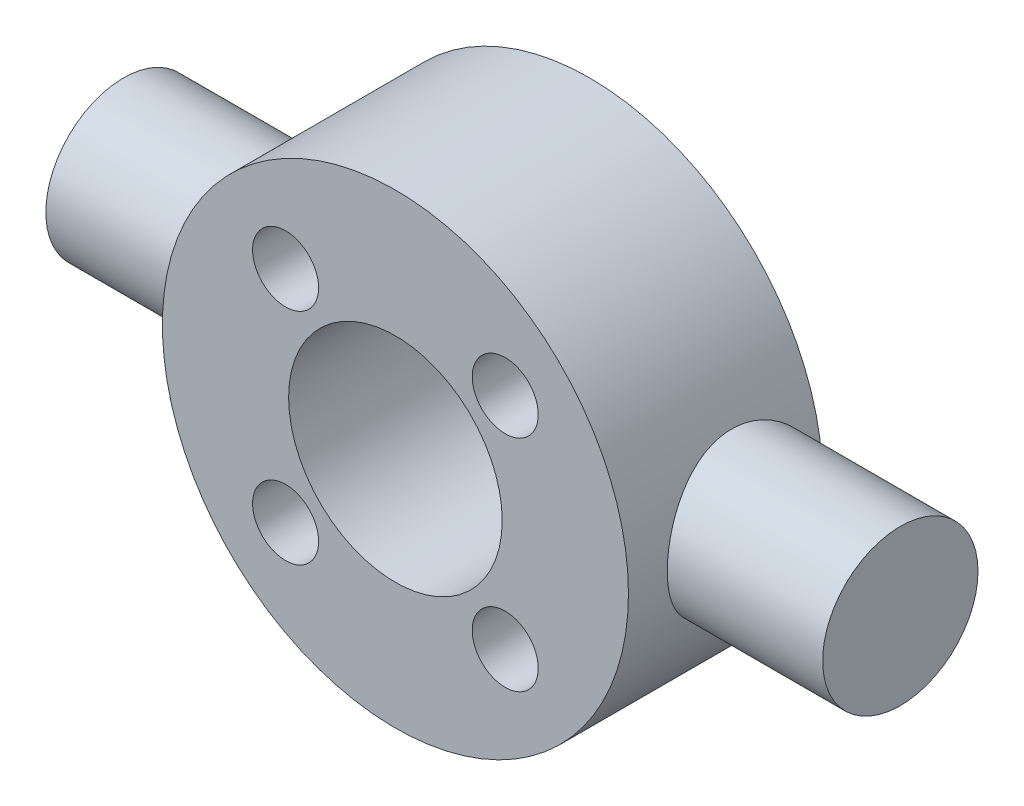
from build123d import *

# Parameters (mm, degrees)
CROQUIS1_R              = 12
CROQUIS1_R_2            = 1.7
SALIENTE_EXTRUIR1_DEPTH = 10
CROQUIS2_R              = 4
SALIENTE_EXTRUIR2_DEPTH = 20
CORTAR_EXTRUIR1_REACH   = 12
CROQUIS3_R              = 5.5


with BuildPart() as part:
    # Croquis1 → Saliente-Extruir1 (new body)
    with BuildSketch(Plane.XY):
        Circle(CROQUIS1_R)
        with Locations((-5.655, 5.655)):
            Circle(CROQUIS1_R_2, mode=Mode.SUBTRACT)
        with Locations((5.655, 5.655)):
            Circle(CROQUIS1_R_2, mode=Mode.SUBTRACT)
        with Locations((5.655, -5.655)):
            Circle(CROQUIS1_R_2, mode=Mode.SUBTRACT)
        with Locations((-5.655, -5.655)):
            Circle(CROQUIS1_R_2, mode=Mode.SUBTRACT)
    extrude(amount=SALIENTE_EXTRUIR1_DEPTH)

    # Croquis2 → Saliente-Extruir2 (add, symmetric)
    with BuildSketch(Plane(origin=(0, 0, 0), x_dir=(0, 0, -1), z_dir=(1, 0, 0))):
        with Locations((-4, 0)):
            Circle(CROQUIS2_R)
    extrude(amount=SALIENTE_EXTRUIR2_DEPTH, both=True)

    # Croquis3 → Cortar-Extruir1 (cut, up to next)
    with BuildSketch(Plane.XY.offset(10), mode=Mode.PRIVATE) as cortar_extruir1_sk1:
        Circle(CROQUIS3_R)
    cortar_extruir1_tool1 = extrude(cortar_extruir1_sk1.sketch, amount=-CORTAR_EXTRUIR1_REACH, mode=Mode.PRIVATE) & part.part
    add(cortar_extruir1_tool1.solids().sort_by_distance((0, 0, 10))[0], mode=Mode.SUBTRACT)


solid = part.part
